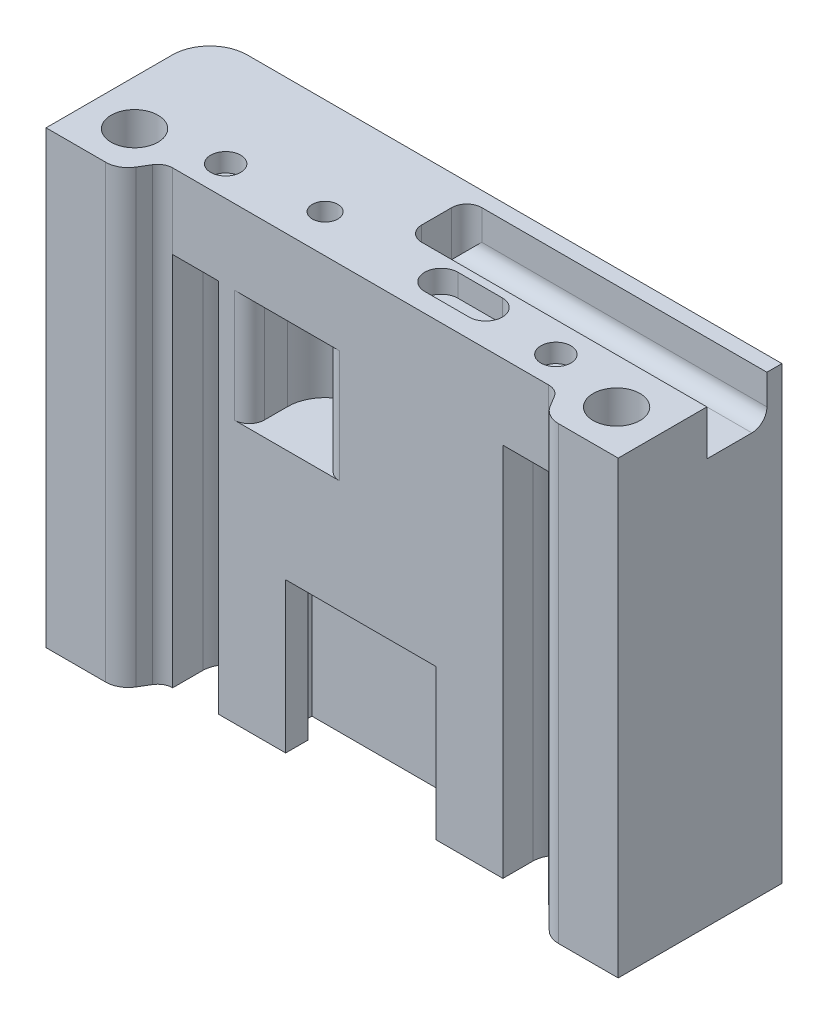
from build123d import *

# Parameters (mm, degrees)
SKETCH1_R           = 2
SKETCH1_R_2         = 3.125
SKETCH1_R_3         = 1.7
BOSS_EXTRUDE1_DEPTH = 10
FILLET2_R           = 3
FILLET1_R           = 2
SKETCH1_4_R         = 3.125
CUT_EXTRUDE3_DEPTH  = 5.07
SKETCH1_7_R         = 1.7
CUT_EXTRUDE6_DEPTH  = 10
CUT_EXTRUDE5_DEPTH  = 3
SKETCH1_5_R         = 2
CUT_EXTRUDE4_DEPTH  = 2.48
SKETCH4_R           = 1.5
CUT_EXTRUDE7_DEPTH  = 10
SKETCH5_R           = 2.725
CUT_EXTRUDE8_DEPTH  = 2.8
BOSS_EXTRUDE2_DEPTH = 10
BOSS_EXTRUDE3_DEPTH = 50
FILLET13_R          = 5
CUT_EXTRUDE14_DEPTH = 15
SKETCH10_W          = 8
SKETCH10_H          = 6
CUT_EXTRUDE12_DEPTH = 40
FILLET12_R          = 2
FILLET14_R          = 2
CUT_EXTRUDE17_DEPTH = 20
SKETCH19_R          = 1.5
CUT_EXTRUDE18_DEPTH = 4


with BuildPart() as part:
    # Sketch1 → Boss-Extrude1 (new body)
    with BuildSketch(Plane(origin=(0, 0, 0), x_dir=(1, 0, 0), z_dir=(0, 1, 0))):
        with BuildLine():
            ThreePointArc((-11.409245094, 8.977987014), (-9.849239736, 9.28), (-8.289234378, 8.977987014))
            ThreePointArc((-8.289234378, 8.977987014), (-5.835653376, 8.254222737), (-3.289234378, 8.01))
            Line((-3.289234378, 8.01), (38.12, 8.01))
            Line((38.12, 8.01), (38.12, -3.81))
            Line((38.12, -3.81), (28.478275237, -3.81))
            Line((28.478275237, -3.81), (26.178275237, 0))
            Line((26.178275237, 0), (-26.178275237, 0))
            Line((-26.178275237, 0), (-28.478275237, -3.81))
            Line((-28.478275237, -3.81), (-38.12, -3.81))
            Line((-38.12, -3.81), (-38.12, 8.01))
            Line((-38.12, 8.01), (-16.409245094, 8.01))
            ThreePointArc((-16.409245094, 8.01), (-13.862826096, 8.254222737), (-11.409245094, 8.977987014))
        make_face()
        with Locations((22, 4.005)):
            Circle(SKETCH1_R, mode=Mode.SUBTRACT)
        with Locations((-22, 4.005)):
            Circle(SKETCH1_R, mode=Mode.SUBTRACT)
        with Locations((-32.12, 1.98)):
            Circle(SKETCH1_R_2, mode=Mode.SUBTRACT)
        with Locations((32.12, 1.98)):
            Circle(SKETCH1_R_2, mode=Mode.SUBTRACT)
        with Locations((-9.849239736, 5.1)):
            Circle(SKETCH1_R_3, mode=Mode.SUBTRACT)
        with BuildLine():
            ThreePointArc((11.912105026, 2.53), (14.127105026, 4.745), (11.912105026, 6.96))
            Line((11.912105026, 6.96), (5.992105026, 6.96))
            ThreePointArc((5.992105026, 6.96), (3.777105026, 4.745), (5.992105026, 2.53))
            Line((5.992105026, 2.53), (11.912105026, 2.53))
        make_face(mode=Mode.SUBTRACT)
        with Locations((-22, 4.005)):
            Circle(SKETCH1_R)
        with Locations((-9.849239736, 5.1)):
            Circle(SKETCH1_R_3)
        with Locations((-32.12, 1.98)):
            Circle(SKETCH1_R_2)
        with BuildLine():
            Line((5.992105026, 2.53), (11.912105026, 2.53))
            ThreePointArc((11.912105026, 2.53), (14.127105026, 4.745), (11.912105026, 6.96))
            Line((11.912105026, 6.96), (5.992105026, 6.96))
            ThreePointArc((5.992105026, 6.96), (3.777105026, 4.745), (5.992105026, 2.53))
        make_face()
        with Locations((22, 4.005)):
            Circle(SKETCH1_R)
        with Locations((32.12, 1.98)):
            Circle(SKETCH1_R_2)
    extrude(amount=-BOSS_EXTRUDE1_DEPTH)

    # Fillet2
    fillet2_edges = [part.edges().sort_by_distance(p)[0] for p in [
        (28.478275237, -5, 3.81),
        (-28.478275237, -5, 3.81),
    ]]
    fillet(fillet2_edges, radius=FILLET2_R)

    # Fillet1
    fillet1_edges = [part.edges().sort_by_distance(p)[0] for p in [
        (26.178275237, -5, 0),
        (-26.178275237, -5, 0),
    ]]
    fillet(fillet1_edges, radius=FILLET1_R)

    # Sketch1_4 → Cut-Extrude3 (cut)
    with BuildSketch(Plane(origin=(0, 0, 0), x_dir=(1, 0, 0), z_dir=(0, 1, 0))):
        with Locations(Location((32.12, 1.98, 0), (0, 0, 270))):
            Circle(SKETCH1_4_R)
        with Locations(Location((-32.12, 1.98, 0), (0, 0, 270))):
            Circle(SKETCH1_4_R)
    extrude(amount=-CUT_EXTRUDE3_DEPTH, mode=Mode.SUBTRACT)

    # Sketch1_7 → Cut-Extrude6 (cut)
    with BuildSketch(Plane(origin=(0, 0, 0), x_dir=(1, 0, 0), z_dir=(0, 1, 0))):
        with Locations(Location((-9.849239736, 5.1, 0), (0, 0, 270))):
            Circle(SKETCH1_7_R)
    extrude(amount=-CUT_EXTRUDE6_DEPTH, mode=Mode.SUBTRACT)

    # Sketch1_6 → Cut-Extrude5 (cut)
    with BuildSketch(Plane(origin=(0, 0, 0), x_dir=(1, 0, 0), z_dir=(0, 1, 0))):
        with BuildLine():
            Line((5.992105026, 2.53), (11.912105026, 2.53))
            ThreePointArc((11.912105026, 2.53), (14.127105026, 4.745), (11.912105026, 6.96))
            Line((11.912105026, 6.96), (5.992105026, 6.96))
            ThreePointArc((5.992105026, 6.96), (3.777105026, 4.745), (5.992105026, 2.53))
        make_face()
    extrude(amount=-CUT_EXTRUDE5_DEPTH, mode=Mode.SUBTRACT)

    # Sketch1_5 → Cut-Extrude4 (cut)
    with BuildSketch(Plane(origin=(0, 0, 0), x_dir=(1, 0, 0), z_dir=(0, 1, 0))):
        with Locations(Location((-22, 4.005, 0), (0, 0, 270))):
            Circle(SKETCH1_5_R)
        with Locations(Location((22, 4.005, 0), (0, 0, 270))):
            Circle(SKETCH1_5_R)
    extrude(amount=-CUT_EXTRUDE4_DEPTH, mode=Mode.SUBTRACT)

    # Sketch4 → Cut-Extrude7 (cut)
    with BuildSketch(Plane(origin=(0, 0, 0), x_dir=(1, 0, 0), z_dir=(0, 1, 0))):
        with Locations(Location((-22, 4.005, 0), (0, 0, 270))):
            Circle(SKETCH4_R)
        with Locations(Location((22, 4.005, 0), (0, 0, 270))):
            Circle(SKETCH4_R)
    extrude(amount=-CUT_EXTRUDE7_DEPTH, mode=Mode.SUBTRACT)

    # Sketch5 → Cut-Extrude8 (cut)
    with BuildSketch(Plane.XZ.offset(10)):
        with Locations(Location((22, -4.005, 0), (0, 0, 270))):
            Circle(SKETCH5_R)
        with Locations(Location((-22, -4.005, 0), (0, 0, 90))):
            Circle(SKETCH5_R)
    extrude(amount=-CUT_EXTRUDE8_DEPTH, mode=Mode.SUBTRACT)

    # Sketch6 → Boss-Extrude2 (add)
    with BuildSketch(Plane(origin=(0, 0, 0), x_dir=(1, 0, 0), z_dir=(0, 1, 0))):
        with BuildLine():
            Line((-38.12, 8.01), (-38.12, 18.01))
            Line((-38.12, 18.01), (38.12, 18.01))
            Line((38.12, 18.01), (38.12, 8.01))
            Line((38.12, 8.01), (-3.289234378, 8.01))
            ThreePointArc((-3.289234378, 8.01), (-5.835653376, 8.254222737), (-8.289234378, 8.977987014))
            ThreePointArc((-8.289234378, 8.977987014), (-9.849239736, 9.28), (-11.409245094, 8.977987014))
            ThreePointArc((-11.409245094, 8.977987014), (-13.862826096, 8.254222737), (-16.409245094, 8.01))
            Line((-16.409245094, 8.01), (-38.12, 8.01))
        make_face()
    extrude(amount=-BOSS_EXTRUDE2_DEPTH)

    # Sketch8 → Boss-Extrude3 (add)
    with BuildSketch(Plane.XZ.offset(10)):
        with BuildLine():
            Line((18.950546011, 0), (-18.950546011, 0))
            Line((-18.950546011, 0), (-18.950546011, -4.005))
            ThreePointArc((-18.950546011, -4.005), (-22, -7.054453989), (-25.049453989, -4.005))
            Line((-25.049453989, -4.005), (-25.049453989, 0))
            ThreePointArc((-25.049453989, 0), (-26.032503369, 0.25827272), (-26.761657912, 0.966386084))
            Line((-26.761657912, 0.966386084), (-27.603201224, 2.360420875))
            ThreePointArc((-27.603201224, 2.360420875), (-28.696933037, 3.422590919), (-30.171507108, 3.81))
            Line((-30.171507108, 3.81), (-38.12, 3.81))
            Line((-38.12, 3.81), (-38.12, -18.01))
            Line((-38.12, -18.01), (38.12, -18.01))
            Line((38.12, -18.01), (38.12, 3.81))
            Line((38.12, 3.81), (30.171507108, 3.81))
            ThreePointArc((30.171507108, 3.81), (28.696933037, 3.422590919), (27.603201224, 2.360420875))
            Line((27.603201224, 2.360420875), (26.761657912, 0.966386084))
            ThreePointArc((26.761657912, 0.966386084), (26.032503369, 0.25827272), (25.049453989, 0))
            Line((25.049453989, 0), (25.049453989, -4.005))
            ThreePointArc((25.049453989, -4.005), (22, -7.054453989), (18.950546011, -4.005))
            Line((18.950546011, -4.005), (18.950546011, 0))
        make_face()
    extrude(amount=BOSS_EXTRUDE3_DEPTH)

    # Fillet13
    fillet13_edges = [part.edges().sort_by_distance(p)[0] for p in [
        (-38.12, -30, -18.01),
    ]]
    fillet(fillet13_edges, radius=FILLET13_R)

    # Sketch8_3 → Cut-Extrude14 (cut)
    with BuildSketch(Plane.XZ.offset(10)):
        with BuildLine():
            Line((-4.849239736, 0), (-4.849239736, -5.1))
            ThreePointArc((-4.849239736, -5.1), (-9.849239736, -10.1), (-14.849239736, -5.1))
            Line((-14.849239736, -5.1), (-14.849239736, 0))
            Line((-14.849239736, 0), (-4.849239736, 0))
        make_face()
    extrude(amount=CUT_EXTRUDE14_DEPTH, mode=Mode.SUBTRACT)

    # Sketch10 → Cut-Extrude12 (cut)
    with BuildSketch(Plane(origin=(38.12, 0, 0), x_dir=(0, 0, -1), z_dir=(1, 0, 0))):
        with Locations((12.01, -3)):
            Rectangle(SKETCH10_W, SKETCH10_H)
    extrude(amount=-CUT_EXTRUDE12_DEPTH, mode=Mode.SUBTRACT)

    # Fillet12
    fillet12_edges = [part.edges().sort_by_distance(p)[0] for p in [
        (-4.849239736, -17.5, 0),
        (-14.849239736, -17.5, 0),
    ]]
    fillet(fillet12_edges, radius=FILLET12_R)

    # Fillet14
    fillet14_edges = [part.edges().sort_by_distance(p)[0] for p in [
        (-1.88, -3, -16.01),
        (18.12, -6, -16.01),
        (-1.88, -3, -8.01),
    ]]
    fillet(fillet14_edges, radius=FILLET14_R)

    # Sketch18 → Cut-Extrude17 (cut)
    with BuildSketch(Plane.XZ.offset(60)):
        Polygon((-10, 0), (-10, -3), (-12.5, -3), (-12.5, -6), (12.5, -6), (12.5, -3), (10, -3), (10, 0), align=None)
    extrude(amount=-CUT_EXTRUDE17_DEPTH, mode=Mode.SUBTRACT)

    # Sketch19 → Cut-Extrude18 (cut)
    with BuildSketch(Plane.XY.offset(-6)):
        with Locations((0, -44)):
            Circle(SKETCH19_R)
    extrude(amount=-CUT_EXTRUDE18_DEPTH, mode=Mode.SUBTRACT)


solid = part.part
